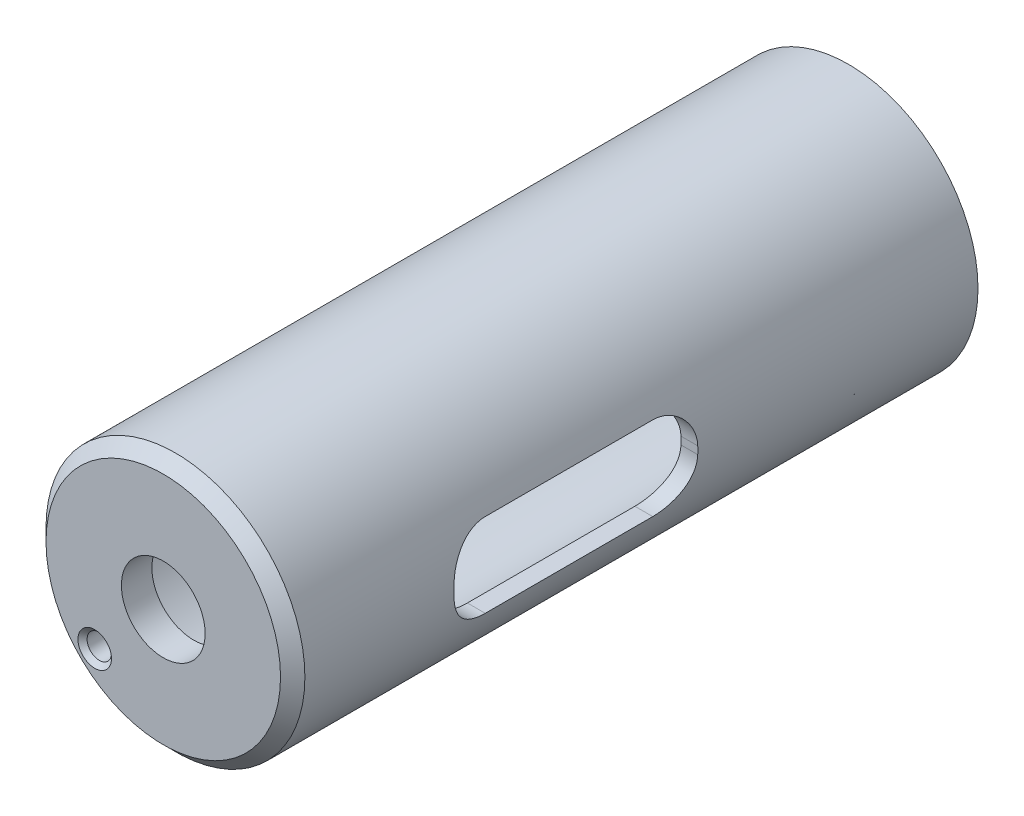
from build123d import *

# Parameters (mm, degrees)
CUT_EXTRUDE_1_DEPTH = 47.577891751
CHAMFER_1_SIZE      = 0.8


with BuildPart() as part:
    # Эскиз1 → Повернуть1 (revolve)
    with BuildSketch(Plane(origin=(0, 0, 0), x_dir=(0, 0, -1), z_dir=(1, 0, 0))):
        Polygon((0, 2.75), (0, 8.5), (45, 8.5), (45, 7.4), (2, 7.4), (2, 2.75), align=None)
    revolve(axis=Axis((0, 0, 0), (0, 0, -1)))

    # Эскиз2 → Вырез-Вытянуть1 (cut, through all)
    with BuildSketch(Plane(origin=(0, 0, 0), x_dir=(0, 0, -1), z_dir=(1, 0, 0))):
        with BuildLine():
            Line((13.1, -2.75), (24.1, -2.75))
            ThreePointArc((24.1, -2.75), (25.867766953, -2.017766953), (26.6, -0.25))
            Line((26.6, -0.25), (26.6, 0.25))
            ThreePointArc((26.6, 0.25), (25.867766953, 2.017766953), (24.1, 2.75))
            Line((24.1, 2.75), (13.1, 2.75))
            ThreePointArc((13.1, 2.75), (11.332233047, 2.017766953), (10.6, 0.25))
            Line((10.6, 0.25), (10.6, -0.25))
            ThreePointArc((10.6, -0.25), (11.332233047, -2.017766953), (13.1, -2.75))
        make_face()
    extrude(amount=CUT_EXTRUDE_1_DEPTH, mode=Mode.SUBTRACT)

    # Фаска1
    chamfer_1_edges = [part.edges().sort_by_distance(p)[0] for p in [
        (0, -8.5, 0),
    ]]
    chamfer(chamfer_1_edges, length=CHAMFER_1_SIZE)

    # Эскиз4 → Отверстие обработанное метчиком M2x0.41 (revolve, cut)
    with BuildSketch(Plane(origin=(-4.5, -4.5, 0), x_dir=(0, -1, 0), z_dir=(1, 0, 0))):
        Polygon((0, 0), (0, 2), (1.05, 2), (0.8, 1.75), (0.8, 0.3), (1.1, 0), align=None)
    revolve(axis=Axis((-4.5, -4.5, 6.35), (0, 0, -1)), mode=Mode.SUBTRACT)


solid = part.part
